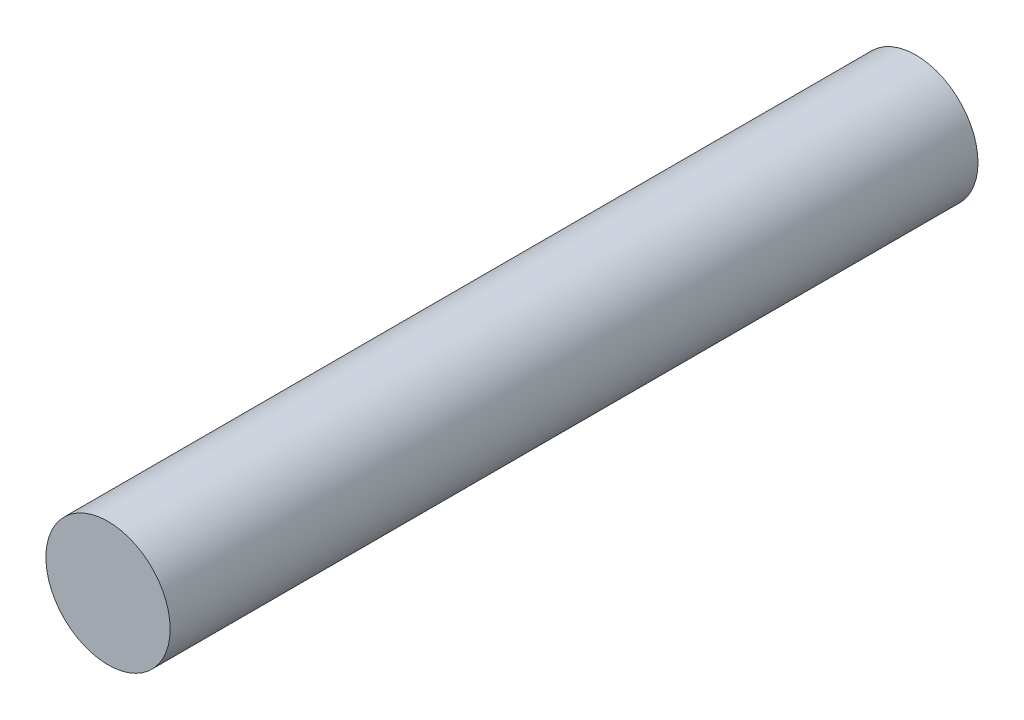
from build123d import *

# Parameters (mm, degrees)
SKETCH1_R           = 5
BOSS_EXTRUDE1_DEPTH = 65


with BuildPart() as part:
    # Sketch1 → Boss-Extrude1 (new body)
    with BuildSketch(Plane.XY):
        Circle(SKETCH1_R)
    extrude(amount=BOSS_EXTRUDE1_DEPTH)


solid = part.part
